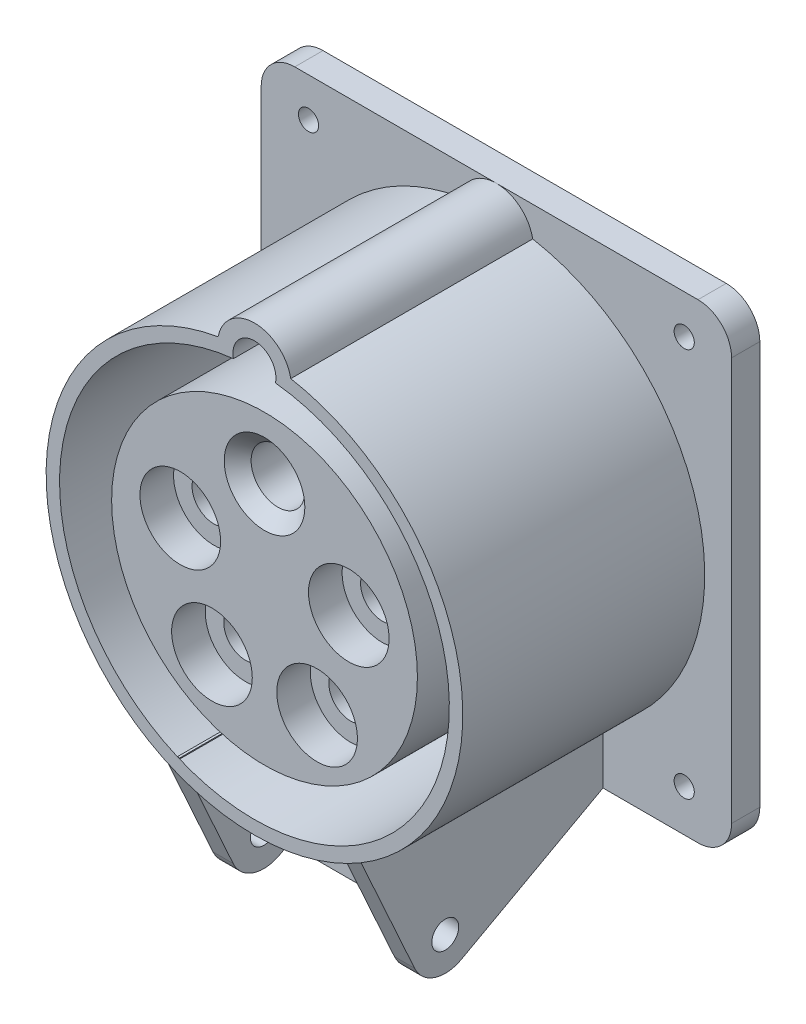
from build123d import *

# Parameters (mm, degrees)
BOSS_EXTRUDE1_DEPTH      = 36
SKETCH4_W                = 70
SKETCH4_H                = 70
SKETCH4_R                = 1.5
BOSS_EXTRUDE2_DEPTH      = 4.2
FILLET1_R                = 5
SKETCH3_R                = 22.75
CUT_EXTRUDE1_DEPTH       = 38.5
SKETCH7_R                = 22.75
CUT_EXTRUDE2_DEPTH       = 1.5
SKETCH9_R                = 6
CUT_EXTRUDE3_DEPTH       = 5
SKETCH11_R               = 3.25
CUT_EXTRUDE4_DEPTH       = 12
SKETCH12_R               = 4
CUT_EXTRUDE5_DEPTH       = 22.7
SKETCH14_R               = 4
CUT_EXTRUDE6_DEPTH       = 8
CHAMFER1_SIZE            = 2
SKETCH15_R               = 5
CUT_EXTRUDE7_DEPTH       = 31.7
SKETCH16_R               = 27.5
SKETCH16_R_2             = 25.2
BOSS_EXTRUDE3_DEPTH      = 2.7
SKETCH17_R               = 2
BOSS_EXTRUDE4_DEPTH      = 3
BOSS_EXTRUDE5_DEPTH      = 0.8
BOSS_EXTRUDE5_DEPTH_BACK = 0.8
SKETCH20_W               = 24
SKETCH20_H               = 22.523679835
BOSS_EXTRUDE6_DEPTH      = 2
FILLET2_R                = 5


with BuildPart() as part:
    # Sketch2 → Boss-Extrude1 (new body)
    with BuildSketch(Plane.XY):
        with BuildLine():
            ThreePointArc((-6.268429979, 33.450707057), (-0.864865769, -28.074716672), (4.538698442, 33.450707057))
            ThreePointArc((4.538698442, 33.450707057), (-0.864865769, 37.925283328), (-6.268429979, 33.450707057))
        make_face()
    extrude(amount=BOSS_EXTRUDE1_DEPTH)

    # Sketch4 → Boss-Extrude2 (add)
    with BuildSketch(Plane(origin=(0, 0, 0), x_dir=(-1, 0, 0), z_dir=(0, 0, -1))):
        with Locations((0.864865769, 2.925283328)):
            Rectangle(SKETCH4_W, SKETCH4_H)
        with Locations((-27.085134231, -25.824716672)):
            Circle(SKETCH4_R, mode=Mode.SUBTRACT)
        with Locations((-27.085134231, 32.109962946)):
            Circle(SKETCH4_R, mode=Mode.SUBTRACT)
        with Locations((28.814865769, 32.109962946)):
            Circle(SKETCH4_R, mode=Mode.SUBTRACT)
        with Locations((28.814865769, -25.824716672)):
            Circle(SKETCH4_R, mode=Mode.SUBTRACT)
    extrude(amount=BOSS_EXTRUDE2_DEPTH)

    # Fillet1
    fillet1_edges = [part.edges().sort_by_distance(p)[0] for p in [
        (-35.864865769, -32.074716672, -2.1),
        (-35.864865769, 37.925283328, -2.1),
        (34.135134231, 37.925283328, -2.1),
        (34.135134231, -32.074716672, -2.1),
    ]]
    fillet(fillet1_edges, radius=FILLET1_R)

    # Sketch3 → Cut-Extrude1 (cut)
    with BuildSketch(Plane.XY.offset(36)):
        with BuildLine():
            ThreePointArc((-3.994084204, 31.755961294), (-0.864865769, -26.074716672), (2.264352666, 31.755961294))
            ThreePointArc((2.264352666, 31.755961294), (-0.864865769, 35.625283328), (-3.994084204, 31.755961294))
        make_face()
        with Locations((-0.864865769, 2.925283328)):
            Circle(SKETCH3_R, mode=Mode.SUBTRACT)
    extrude(amount=-CUT_EXTRUDE1_DEPTH, mode=Mode.SUBTRACT)

    # Sketch7 → Cut-Extrude2 (cut)
    with BuildSketch(Plane.XY.offset(36)):
        with Locations((-0.864865769, 2.925283328)):
            Circle(SKETCH7_R)
    extrude(amount=-CUT_EXTRUDE2_DEPTH, mode=Mode.SUBTRACT)

    # Sketch9 → Cut-Extrude3 (cut)
    with BuildSketch(Plane.XY.offset(34.5)):
        with Locations((-8.68550449, -9.468077043)):
            Circle(SKETCH9_R)
        with Locations((-13.403571753, 5.757891252)):
            Circle(SKETCH9_R)
        with Locations((11.673840215, 5.757891252)):
            Circle(SKETCH9_R)
        with Locations((6.955772953, -9.468077043)):
            Circle(SKETCH9_R)
    extrude(amount=-CUT_EXTRUDE3_DEPTH, mode=Mode.SUBTRACT)

    # Sketch11 → Cut-Extrude4 (cut)
    with BuildSketch(Plane.XY.offset(29.5)):
        with Locations((11.673840215, 5.757891252)):
            Circle(SKETCH11_R)
        with Locations((-13.403571753, 5.757891252)):
            Circle(SKETCH11_R)
        with Locations((-8.68550449, -9.468077043)):
            Circle(SKETCH11_R)
        with Locations((6.955772953, -9.468077043)):
            Circle(SKETCH11_R)
    extrude(amount=-CUT_EXTRUDE4_DEPTH, mode=Mode.SUBTRACT)

    # Sketch12 → Cut-Extrude5 (cut, through all)
    with BuildSketch(Plane.XY.offset(17.5)):
        with Locations((11.673840215, 5.757891252)):
            Circle(SKETCH12_R)
        with Locations((6.955772953, -9.468077043)):
            Circle(SKETCH12_R)
        with Locations((-8.68550449, -9.468077043)):
            Circle(SKETCH12_R)
        with Locations((-13.403571753, 5.757891252)):
            Circle(SKETCH12_R)
    extrude(amount=-CUT_EXTRUDE5_DEPTH, mode=Mode.SUBTRACT)

    # Sketch14 → Cut-Extrude6 (cut)
    with BuildSketch(Plane.XY.offset(34.5)):
        with Locations((-0.864865769, 16.425283328)):
            Circle(SKETCH14_R)
    extrude(amount=-CUT_EXTRUDE6_DEPTH, mode=Mode.SUBTRACT)

    # Chamfer1
    chamfer1_edges = [part.edges().sort_by_distance(p)[0] for p in [
        (-4.864865769, 16.425283328, 34.5),
    ]]
    chamfer(chamfer1_edges, length=CHAMFER1_SIZE)

    # Sketch15 → Cut-Extrude7 (cut, through all)
    with BuildSketch(Plane.XY.offset(26.5)):
        with Locations((-0.864865769, 16.425283328)):
            Circle(SKETCH15_R)
    extrude(amount=-CUT_EXTRUDE7_DEPTH, mode=Mode.SUBTRACT)

    # Sketch16 → Boss-Extrude3 (add)
    with BuildSketch(Plane(origin=(0, 0, -4.2), x_dir=(-1, 0, 0), z_dir=(0, 0, -1))):
        with Locations((0.864865769, 2.925283328)):
            Circle(SKETCH16_R)
        with Locations((0.864865769, 2.925283328)):
            Circle(SKETCH16_R_2, mode=Mode.SUBTRACT)
    extrude(amount=BOSS_EXTRUDE3_DEPTH)

    # Sketch17 → Boss-Extrude4 (add)
    with BuildSketch(Plane(origin=(15, 0, 0), x_dir=(0, 0, -1), z_dir=(1, 0, 0))):
        Polygon((-36, -23.70751664), (-25.8, -46.20751664), (0, -32.074716672), (0, -23.70751664), align=None)
        with Locations((-23.472627315, -39.231599401)):
            Circle(SKETCH17_R, mode=Mode.SUBTRACT)
    boss_extrude4 = extrude(amount=-BOSS_EXTRUDE4_DEPTH)

    # Mirror1: Boss-Extrude4 across plane
    add(boss_extrude4.mirror(Plane(origin=(0, 0, 0), x_dir=(0, 0, 1), z_dir=(1, 0, 0))))

    # Sketch19 → Boss-Extrude5 (add, two sides)
    with BuildSketch(Plane(origin=(0, 0, 0), x_dir=(0, 0, -1), z_dir=(1, 0, 0))) as boss_extrude5_sk:
        Polygon((0, -26.005820793), (0, -32.074716672), (-18, -41.934809673), (-18, -26.005820793), align=None)
    extrude(amount=BOSS_EXTRUDE5_DEPTH)
    extrude(boss_extrude5_sk.sketch, amount=-BOSS_EXTRUDE5_DEPTH_BACK)

    # Sketch20 → Boss-Extrude6 (add, along a direction that is not the sketch's normal)
    with BuildSketch(Plane(origin=(0, -24.671603492, -13.514683606), x_dir=(1, 0, 0), z_dir=(0, -0.877035704, -0.480425201))):
        with Locations((0, 26.671342108)):
            Rectangle(SKETCH20_W, SKETCH20_H)
    extrude(amount=-BOSS_EXTRUDE6_DEPTH, dir=(0, -1, 0))

    # Fillet2
    fillet2_edges = [part.edges().sort_by_distance(p)[0] for p in [
        (13.5, -46.20751664, 25.8),
        (-13.5, -46.20751664, 25.8),
    ]]
    fillet(fillet2_edges, radius=FILLET2_R)


solid = part.part
